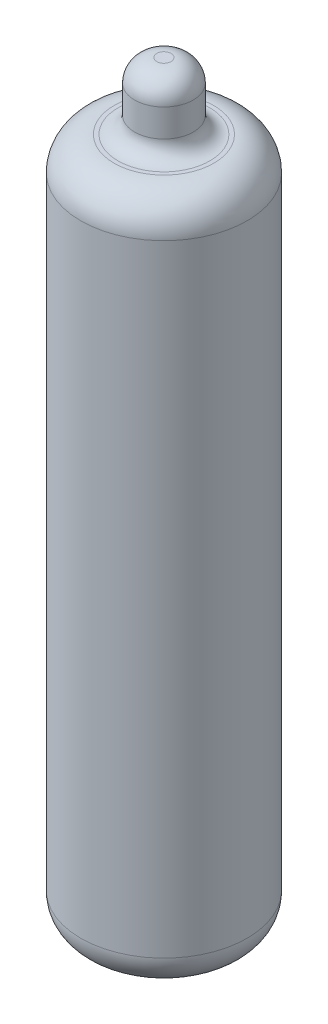
from build123d import *


with BuildPart() as part:
    # Esquisse1 → Révolution1 (revolve)
    with BuildSketch(Plane.XY):
        with BuildLine():
            Line((0, 0), (4.5, 0))
            ThreePointArc((4.5, 0), (6.621320344, 0.878679656), (7.5, 3))
            Line((7.5, 3), (7.5, 59))
            ThreePointArc((7.5, 59), (6.621320344, 61.121320344), (4.5, 62))
            Line((4.5, 62), (4.140675016, 62))
            ThreePointArc((4.140675016, 62), (3.080014844, 62.439339828), (2.640675016, 63.5))
            Line((2.640675016, 63.5), (2.640675016, 66))
            ThreePointArc((2.640675016, 66), (2.054888578, 67.414213562), (0.640675016, 68))
            Line((0.640675016, 68), (0, 68))
            Line((0, 68), (0, 0))
        make_face()
    revolve(axis=Axis((0, 68, 0), (0, -1, 0)))


solid = part.part
